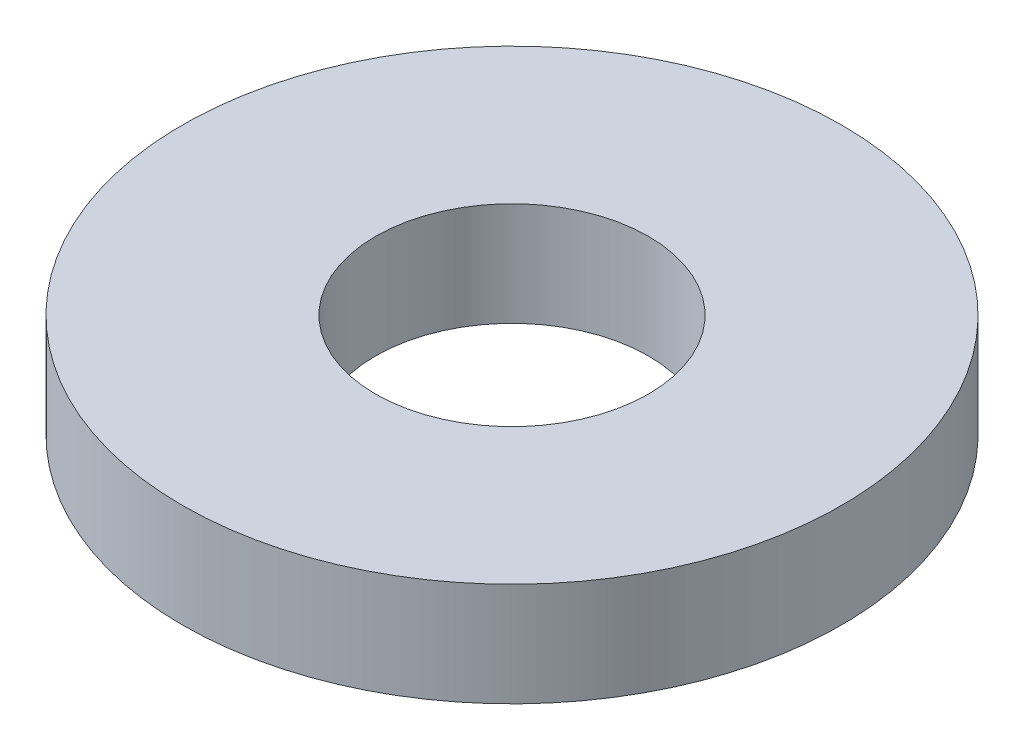
from build123d import *

# Parameters (mm, degrees)
SKETCH1_R           = 3.5
SKETCH1_R_2         = 1.45
BOSS_EXTRUDE1_DEPTH = 1.1


with BuildPart() as part:
    # Sketch1 → Boss-Extrude1 (new body)
    with BuildSketch(Plane(origin=(0, 0, 0), x_dir=(1, 0, 0), z_dir=(0, 1, 0))):
        Circle(SKETCH1_R)
        Circle(SKETCH1_R_2, mode=Mode.SUBTRACT)
    extrude(amount=BOSS_EXTRUDE1_DEPTH)


solid = part.part
